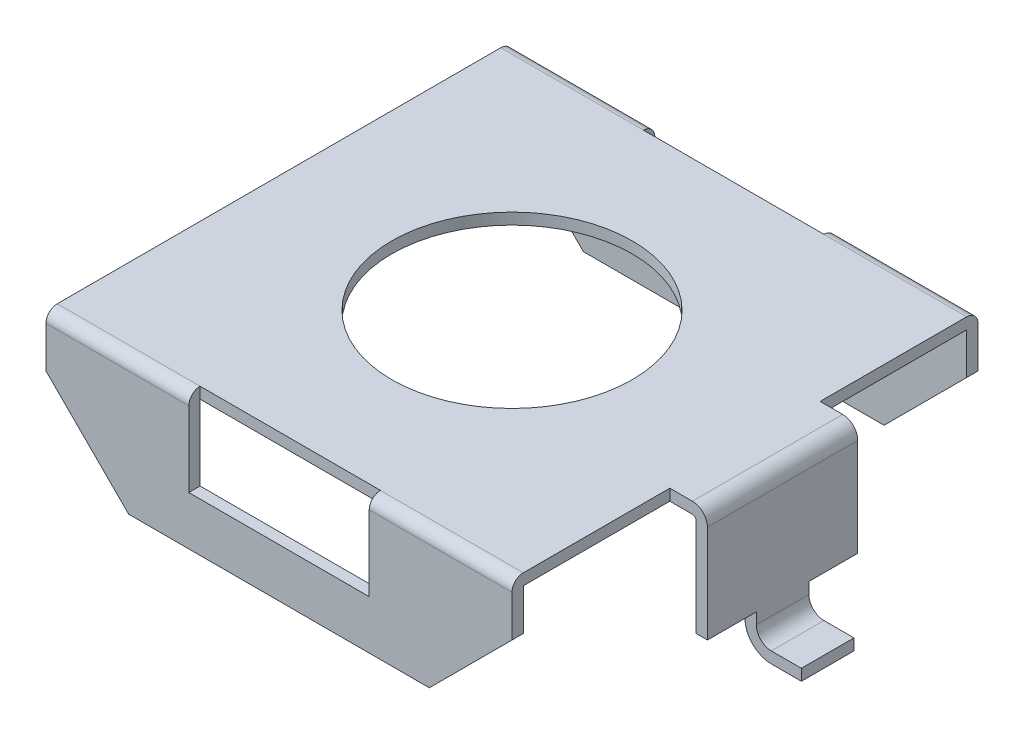
from build123d import *

# Parameters (mm, degrees)
EXTRUDE_THIN3_DEPTH     = 3.1
SKETCH2_W               = 2.4
SKETCH2_H               = 1
CUT_EXTRUDE1_DEPTH      = 4.1
CUT_EXTRUDE1_DEPTH_BACK = 4.1
SKETCH3_W               = 2.4
SKETCH3_H               = 0.15
CUT_EXTRUDE2_DEPTH      = 1
FILLET1_R               = 0.15
SKETCH4_R               = 1.6
CUT_EXTRUDE3_DEPTH      = 1
EXTRUDE_THIN4_DEPTH     = 1
SKETCH6_W               = 1
SKETCH6_H               = 0.65
CUT_EXTRUDE4_DEPTH      = 0.5


with BuildPart() as part:
    # Sketch1 → Extrude-Thin3 (new body, symmetric)
    with BuildSketch(Plane(origin=(0, 0, 0), x_dir=(0, 0, -1), z_dir=(1, 0, 0))):
        Polygon((-3.1, 0.2), (-3.1, 2), (3.1, 2), (3.1, 0.2), (2.95, 0.2), (2.95, 1.85), (-2.95, 1.85), (-2.95, 0.2), align=None)
    extrude(amount=EXTRUDE_THIN3_DEPTH, both=True)

    # Sketch2 → Cut-Extrude1 (cut, two sides)
    with BuildSketch(Plane.XY) as cut_extrude1_sk:
        with Locations((0, 1.35)):
            Rectangle(SKETCH2_W, SKETCH2_H)
        Polygon((-3.1, 1.3), (-2, 0.2), (-3.1, 0.2), align=None)
        Polygon((3.1, 0.2), (3.1, 1.3), (2, 0.2), align=None)
    extrude(amount=CUT_EXTRUDE1_DEPTH, mode=Mode.SUBTRACT)
    extrude(cut_extrude1_sk.sketch, amount=-CUT_EXTRUDE1_DEPTH_BACK, mode=Mode.SUBTRACT)

    # Sketch3 → Cut-Extrude2 (cut)
    with BuildSketch(Plane(origin=(0, 2, 0), x_dir=(1, 0, 0), z_dir=(0, 1, 0))):
        with Locations((0, 3.025)):
            Rectangle(SKETCH3_W, SKETCH3_H)
        with Locations((0, -3.025)):
            Rectangle(SKETCH3_W, SKETCH3_H)
    extrude(amount=-CUT_EXTRUDE2_DEPTH, mode=Mode.SUBTRACT)

    # Fillet1
    fillet1_edges = [part.edges().sort_by_distance(p)[0] for p in [
        (-2.15, 2, -3.1),
        (2.15, 2, -3.1),
        (-2.15, 2, 3.1),
        (2.15, 2, 3.1),
    ]]
    fillet(fillet1_edges, radius=FILLET1_R)

    # Sketch4 → Cut-Extrude3 (cut)
    with BuildSketch(Plane(origin=(0, 2, 0), x_dir=(1, 0, 0), z_dir=(0, 1, 0))):
        with Locations(Location((0, 0, 0), (0, 0, 270))):  # turned: the seam where the file's is
            Circle(SKETCH4_R)
    extrude(amount=-CUT_EXTRUDE3_DEPTH, mode=Mode.SUBTRACT)

    # Sketch5 → Extrude-Thin4 (add, symmetric)
    with BuildSketch(Plane.XY):
        with BuildLine():
            Line((3.1, 2), (3.4, 2))
            ThreePointArc((3.4, 2), (3.541421356, 1.941421356), (3.6, 1.8))
            Line((3.6, 1.8), (3.6, 0.35))
            ThreePointArc((3.6, 0.35), (3.658578644, 0.208578644), (3.8, 0.15))
            Line((3.8, 0.15), (4.2, 0.15))
            Line((4.2, 0.15), (4.2, 0))
            Line((4.2, 0), (3.8, 0))
            ThreePointArc((3.8, 0), (3.552512627, 0.102512627), (3.45, 0.35))
            Line((3.45, 0.35), (3.45, 1.8))
            ThreePointArc((3.45, 1.8), (3.435355339, 1.835355339), (3.4, 1.85))
            Line((3.4, 1.85), (3.1, 1.85))
            Line((3.1, 1.85), (3.1, 2))
        make_face()
    extrude(amount=EXTRUDE_THIN4_DEPTH, both=True)

    # Sketch6 → Cut-Extrude4 (cut)
    with BuildSketch(Plane.XZ):
        with Locations((3.7, 0.675)):
            Rectangle(SKETCH6_W, SKETCH6_H)
        with Locations((3.7, -0.675)):
            Rectangle(SKETCH6_W, SKETCH6_H)
    extrude(amount=-CUT_EXTRUDE4_DEPTH, mode=Mode.SUBTRACT)


solid = part.part
